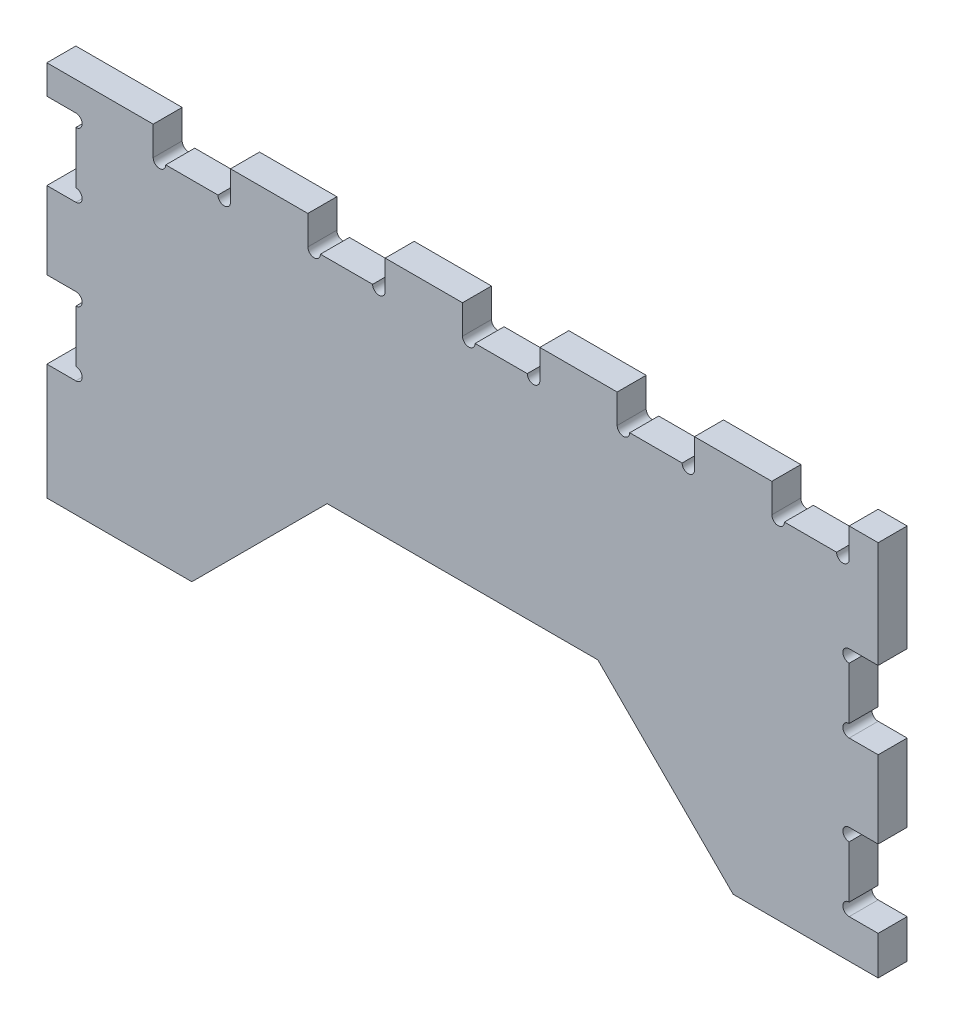
from build123d import *

# Parameters (mm, degrees)
SALIENTE_EXTRUIR1_DEPTH = 15
CROQUIS2_W              = 430
CROQUIS2_H              = 15
SALIENTE_EXTRUIR2_DEPTH = 15
CROQUIS3_W              = 40
CROQUIS3_H              = 19.65418827
CORTAR_EXTRUIR2_DEPTH   = 15
CORTAR_EXTRUIR3_DEPTH   = 15
CORTAR_EXTRUIR4_DEPTH   = 15


with BuildPart() as part:
    # Croquis1 → Saliente-Extruir1 (new body)
    with BuildSketch(Plane.XY):
        Polygon((95, -45), (140, -90), (215, -90), (215, -20), (215, 90), (-215, 90), (-215, -20), (-215, -90), (-140, -90), (-95, -45), (-70, -20), (70, -20), align=None)
    extrude(amount=SALIENTE_EXTRUIR1_DEPTH)

    # Croquis2 → Saliente-Extruir2 (add)
    with BuildSketch(Plane(origin=(0, 90, 0), x_dir=(1, 0, 0), z_dir=(0, 1, 0))):
        with Locations((0, -7.5)):
            Rectangle(CROQUIS2_W, CROQUIS2_H)
    extrude(amount=SALIENTE_EXTRUIR2_DEPTH)

    # Croquis3 → Cortar-Extruir2 (cut)
    with BuildSketch(Plane.XY.offset(15)):
        with Locations((-140, 114.827094135)):
            Rectangle(CROQUIS3_W, CROQUIS3_H)
        with BuildLine():
            Line((-120, 90), (-120, 105))
            Line((-120, 105), (-160, 105))
            Line((-160, 105), (-160, 90))
            ThreePointArc((-160, 90), (-156.75, 86.75), (-153.5, 90))
            Line((-153.5, 90), (-126.5, 90))
            ThreePointArc((-126.5, 90), (-123.25, 86.75), (-120, 90))
        make_face()
        with BuildLine():
            Line((-40, 90), (-40, 105))
            Line((-40, 105), (-80, 105))
            Line((-80, 105), (-80, 90))
            ThreePointArc((-80, 90), (-76.75, 86.75), (-73.5, 90))
            Line((-73.5, 90), (-46.5, 90))
            ThreePointArc((-46.5, 90), (-43.25, 86.75), (-40, 90))
        make_face()
        with Locations((-60, 114.827094135)):
            Rectangle(CROQUIS3_W, CROQUIS3_H)
        with BuildLine():
            Line((40, 105), (0, 105))
            Line((0, 105), (0, 90))
            ThreePointArc((0, 90), (3.25, 86.75), (6.5, 90))
            Line((6.5, 90), (33.5, 90))
            ThreePointArc((33.5, 90), (36.75, 86.75), (40, 90))
            Line((40, 90), (40, 105))
        make_face()
        with Locations((20, 114.827094135)):
            Rectangle(CROQUIS3_W, CROQUIS3_H)
        with BuildLine():
            Line((200, 105), (160, 105))
            Line((160, 105), (160, 90))
            ThreePointArc((160, 90), (163.25, 86.75), (166.5, 90))
            Line((166.5, 90), (193.5, 90))
            ThreePointArc((193.5, 90), (196.75, 86.75), (200, 90))
            Line((200, 90), (200, 105))
        make_face()
        with Locations((180, 114.827094135)):
            Rectangle(CROQUIS3_W, CROQUIS3_H)
        with Locations((100, 114.827094135)):
            Rectangle(CROQUIS3_W, CROQUIS3_H)
        with BuildLine():
            Line((120, 105), (80, 105))
            Line((80, 105), (80, 90))
            ThreePointArc((80, 90), (83.25, 86.75), (86.5, 90))
            Line((86.5, 90), (113.6, 90))
            ThreePointArc((113.6, 90), (116.8, 86.8), (120, 90))
            Line((120, 90), (120, 105))
        make_face()
    extrude(amount=-CORTAR_EXTRUIR2_DEPTH, mode=Mode.SUBTRACT)

    # Croquis4 → Cortar-Extruir3 (cut)
    with BuildSketch(Plane.XY.offset(15)):
        with BuildLine():
            Line((-200, 10), (-215, 10))
            Line((-215, 10), (-215, -30))
            Line((-215, -30), (-200, -30))
            ThreePointArc((-200, -30), (-196.75, -26.75), (-200, -23.5))
            Line((-200, -23.5), (-200, 3.5))
            ThreePointArc((-200, 3.5), (-196.75, 6.75), (-200, 10))
        make_face()
        with BuildLine():
            Line((-215, 90), (-215, 50))
            Line((-215, 50), (-200, 50))
            ThreePointArc((-200, 50), (-196.75, 53.25), (-200, 56.5))
            Line((-200, 56.5), (-200, 83.5))
            ThreePointArc((-200, 83.5), (-196.75, 86.75), (-200, 90))
            Line((-200, 90), (-215, 90))
        make_face()
    extrude(amount=-CORTAR_EXTRUIR3_DEPTH, mode=Mode.SUBTRACT)

    # Croquis5 → Cortar-Extruir4 (cut)
    with BuildSketch(Plane.XY.offset(15)):
        with BuildLine():
            Line((215, 10), (215, 50))
            Line((215, 50), (200, 50))
            ThreePointArc((200, 50), (196.75, 46.75), (200, 43.5))
            Line((200, 43.5), (200, 16.5))
            ThreePointArc((200, 16.5), (196.75, 13.25), (200, 10))
            Line((200, 10), (215, 10))
        make_face()
        with BuildLine():
            Line((215, -70), (215, -30))
            Line((215, -30), (200, -30))
            ThreePointArc((200, -30), (196.75, -33.25), (200, -36.5))
            Line((200, -36.5), (200, -63.5))
            ThreePointArc((200, -63.5), (196.75, -66.75), (200, -70))
            Line((200, -70), (215, -70))
        make_face()
    extrude(amount=-CORTAR_EXTRUIR4_DEPTH, mode=Mode.SUBTRACT)


solid = part.part
